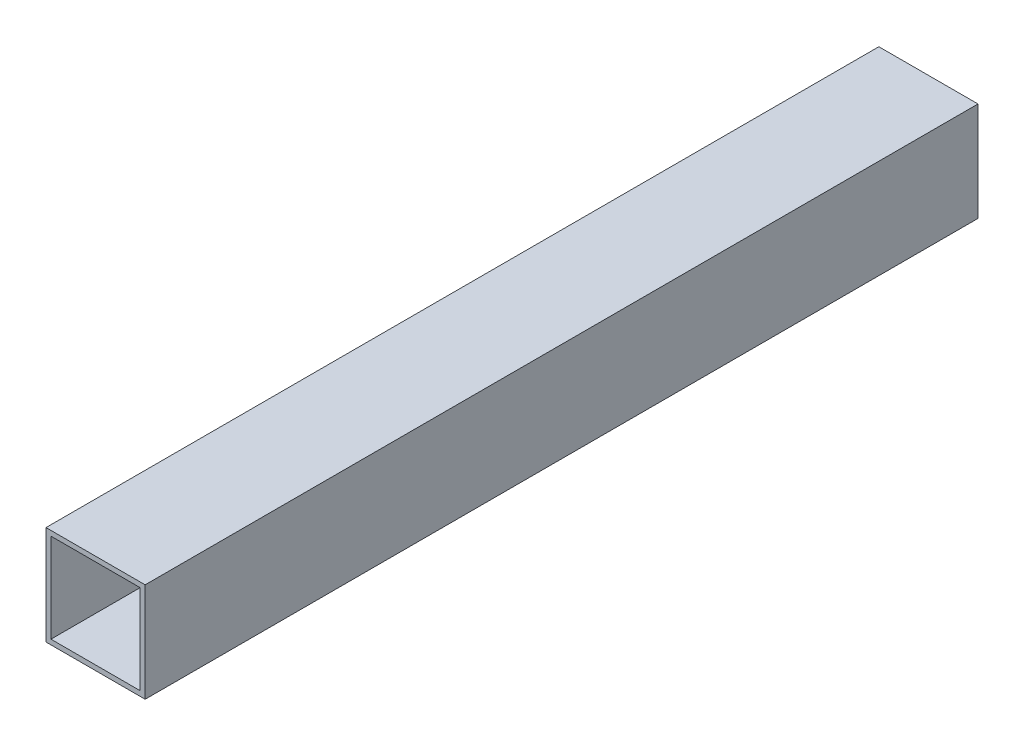
from build123d import *

# Parameters (mm, degrees)
SKETCH1_W           = 100
SKETCH1_H           = 100
SKETCH1_W_2         = 90
SKETCH1_H_2         = 90
BOSS_EXTRUDE1_DEPTH = 420


with BuildPart() as part:
    # Sketch1 → Boss-Extrude1 (new body, symmetric)
    with BuildSketch(Plane.XY):
        Rectangle(SKETCH1_W, SKETCH1_H)
        Rectangle(SKETCH1_W_2, SKETCH1_H_2, mode=Mode.SUBTRACT)
    extrude(amount=BOSS_EXTRUDE1_DEPTH, both=True)


solid = part.part
